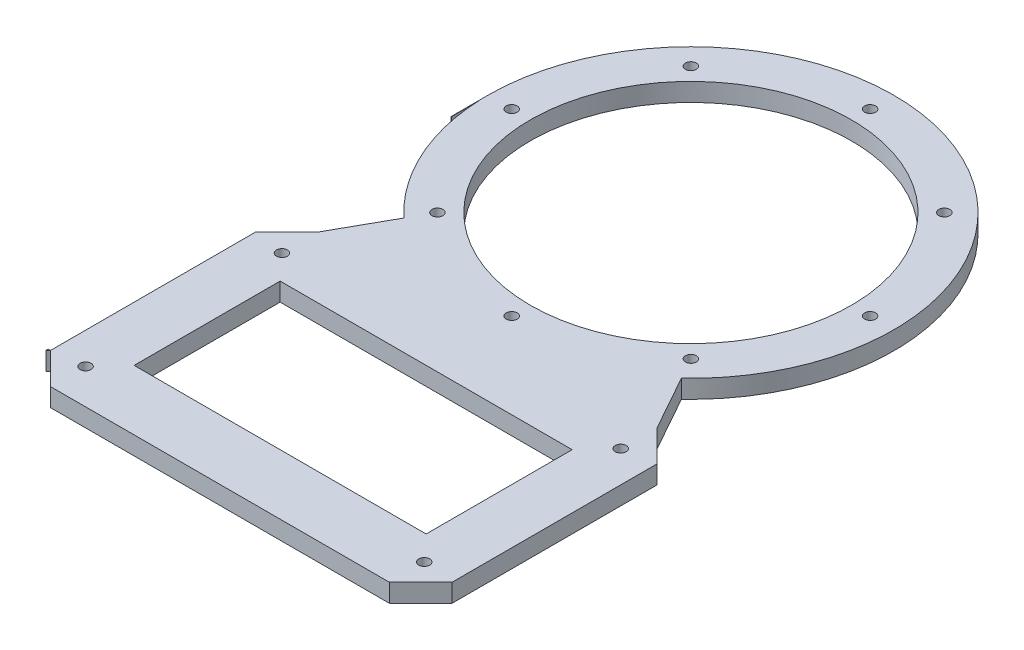
from build123d import *

# Parameters (mm, degrees)
SKETCH_1_R               = 1.5
SKETCH_1_W               = 80
SKETCH_1_H               = 40
SKETCH_1_R_2             = 44
EXTRUDE_1_DEPTH          = 5
SKETCH_3_R               = 1.5
EXTRUDE_2_DEPTH          = 5
SKETCH_3_5_R             = 30
SKETCH_3_5_R_2           = 25
EXTRUDE_3_DEPTH          = 15
CUT_EXTRUDE_1_DEPTH      = 10
CUT_EXTRUDE_1_DEPTH_BACK = 10
SKETCH_4_W               = 124.485015382
SKETCH_4_H               = 203.768364002
SKETCH_5_W               = 73.623406186
SKETCH_5_H               = 110.319230846
CUT_EXTRUDE_2_DEPTH      = 10


with BuildPart() as part:
    # 草图1 → 凸台-拉伸1 (new body)
    with BuildSketch(Plane(origin=(0, 0, 0), x_dir=(1, 0, 0), z_dir=(0, 1, 0))):
        with BuildLine():
            Line((55, -64.230312435), (46.4, -55.630312435))
            Line((46.4, -55.630312435), (38.013398823, -40.616661254))
            ThreePointArc((38.013398823, -40.616661254), (0, 55.630312435), (-38.013398823, -40.616661254))
            Line((-38.013398823, -40.616661254), (-46.4, -55.630312435))
            Line((-46.4, -55.630312435), (-55, -64.230312435))
            Line((-55, -64.230312435), (-55, -120.419438856))
            Line((-55, -120.419438856), (-46.4, -129.019438856))
            Line((-46.4, -129.019438856), (46.4, -129.019438856))
            Line((46.4, -129.019438856), (55, -120.419438856))
            Line((55, -120.419438856), (55, -64.230312435))
        make_face()
        with Locations((-46.4, -65.630312435)):
            Circle(SKETCH_1_R, mode=Mode.SUBTRACT)
        with Locations((-46.4, -119.430312435)):
            Circle(SKETCH_1_R, mode=Mode.SUBTRACT)
        with Locations((46.4, -119.430312435)):
            Circle(SKETCH_1_R, mode=Mode.SUBTRACT)
        with Locations((46.4, -65.630312435)):
            Circle(SKETCH_1_R, mode=Mode.SUBTRACT)
        with Locations((0, -92.530312435)):
            Rectangle(SKETCH_1_W, SKETCH_1_H, mode=Mode.SUBTRACT)
        with Locations((34.718942956, 34.718942956)):
            Circle(SKETCH_1_R, mode=Mode.SUBTRACT)
        with Locations((0, -49.1)):
            Circle(SKETCH_1_R, mode=Mode.SUBTRACT)
        with Locations((-34.718942956, -34.718942956)):
            Circle(SKETCH_1_R, mode=Mode.SUBTRACT)
        with Locations((-49.1, 0)):
            Circle(SKETCH_1_R, mode=Mode.SUBTRACT)
        with Locations((-34.718942956, 34.718942956)):
            Circle(SKETCH_1_R, mode=Mode.SUBTRACT)
        Circle(SKETCH_1_R_2, mode=Mode.SUBTRACT)
        with Locations((34.718942956, -34.718942956)):
            Circle(SKETCH_1_R, mode=Mode.SUBTRACT)
        with Locations((49.1, 0)):
            Circle(SKETCH_1_R, mode=Mode.SUBTRACT)
        with Locations((0, 49.1)):
            Circle(SKETCH_1_R, mode=Mode.SUBTRACT)
    extrude(amount=EXTRUDE_1_DEPTH)

    # 草图3 → 凸台-拉伸2 (add)
    with BuildSketch(Plane(origin=(0, 0, 0), x_dir=(1, 0, 0), z_dir=(0, 1, 0))):
        Polygon((-55, -120.419438856), (-55, -64.230312435), (-55.62678138, 0.62678138), (-55.62678138, 59.784464423), (-63.6, 67.757683044), (-123.6, 67.757683044), (-132.2, 59.157683044), (-132.2, -120.419438856), (-123.6, -129.019438856), (-63.6, -129.019438856), align=None)
        with Locations((-123.6, -120.419438856)):
            Circle(SKETCH_3_R, mode=Mode.SUBTRACT)
        with Locations((-63.6, -120.419438856)):
            Circle(SKETCH_3_R, mode=Mode.SUBTRACT)
        with Locations((-123.6, 59.157683044)):
            Circle(SKETCH_3_R, mode=Mode.SUBTRACT)
        with Locations((-63.6, 59.784464423)):
            Circle(SKETCH_3_R, mode=Mode.SUBTRACT)
    extrude(amount=EXTRUDE_2_DEPTH)

    # 草图3<5> → 凸台-拉伸3 (add)
    # profile 1 of 3: a face of its own
    with BuildSketch(Plane(origin=(0, 0, 0), x_dir=(1, 0, 0), z_dir=(0, 1, 0))):
        with Locations((-93.6, -94.019438856)):
            Circle(SKETCH_3_5_R)
        with Locations((-93.6, -94.019438856)):
            Circle(SKETCH_3_5_R_2, mode=Mode.SUBTRACT)
    # profile 2 of 3: a face of its own
    with BuildSketch(Plane(origin=(0, 0, 0), x_dir=(1, 0, 0), z_dir=(0, 1, 0))):
        with Locations((-93.6, -31.152726962)):
            Circle(SKETCH_3_5_R)
        with Locations((-93.6, -31.152726962)):
            Circle(SKETCH_3_5_R_2, mode=Mode.SUBTRACT)
    # profile 3 of 3: a face of its own
    with BuildSketch(Plane(origin=(0, 0, 0), x_dir=(1, 0, 0), z_dir=(0, 1, 0))):
        with Locations((-93.6, 32.408258162)):
            Circle(SKETCH_3_5_R)
        with Locations((-93.6, 32.408258162)):
            Circle(SKETCH_3_5_R_2, mode=Mode.SUBTRACT)
    extrude(amount=EXTRUDE_3_DEPTH)

    # 草图4 → 切除-拉伸1 (cut, two sides: drawn at the far end of the back side and taken through both)
    with BuildSketch(Plane(origin=(0, 5, 0), x_dir=(1, 0, 0), z_dir=(0, 1, 0)).offset(-CUT_EXTRUDE_1_DEPTH_BACK)):
        with Locations((-117.869289071, -34.126498957)):
            Rectangle(SKETCH_4_W, SKETCH_4_H)
    extrude(amount=CUT_EXTRUDE_1_DEPTH + CUT_EXTRUDE_1_DEPTH_BACK, mode=Mode.SUBTRACT)

    # 草图5 → 切除-拉伸2 (cut)
    with BuildSketch(Plane(origin=(0, 5, 0), x_dir=(1, 0, 0), z_dir=(0, 1, 0))):
        with Locations((-91.811703093, -65.259823433)):
            Rectangle(SKETCH_5_W, SKETCH_5_H)
    extrude(amount=-CUT_EXTRUDE_2_DEPTH, mode=Mode.SUBTRACT)


with BuildPart() as cut_extrude_2_piece_1:
    # of the separate pieces the step leaves, piece 1, a body of its own (cut_extrude_2_pieces)
    add(part.part.solids().sort_by_distance((55, 0, 120.419438856))[0])


with BuildPart() as cut_extrude_2_piece_2:
    # of the separate pieces the step leaves, piece 2, a body of its own (cut_extrude_2_pieces)
    add(part.part.solids().sort_by_distance((-55.62678138, 0, 121.046220236))[0])


solid = Compound([cut_extrude_2_piece_1.part, cut_extrude_2_piece_2.part])
